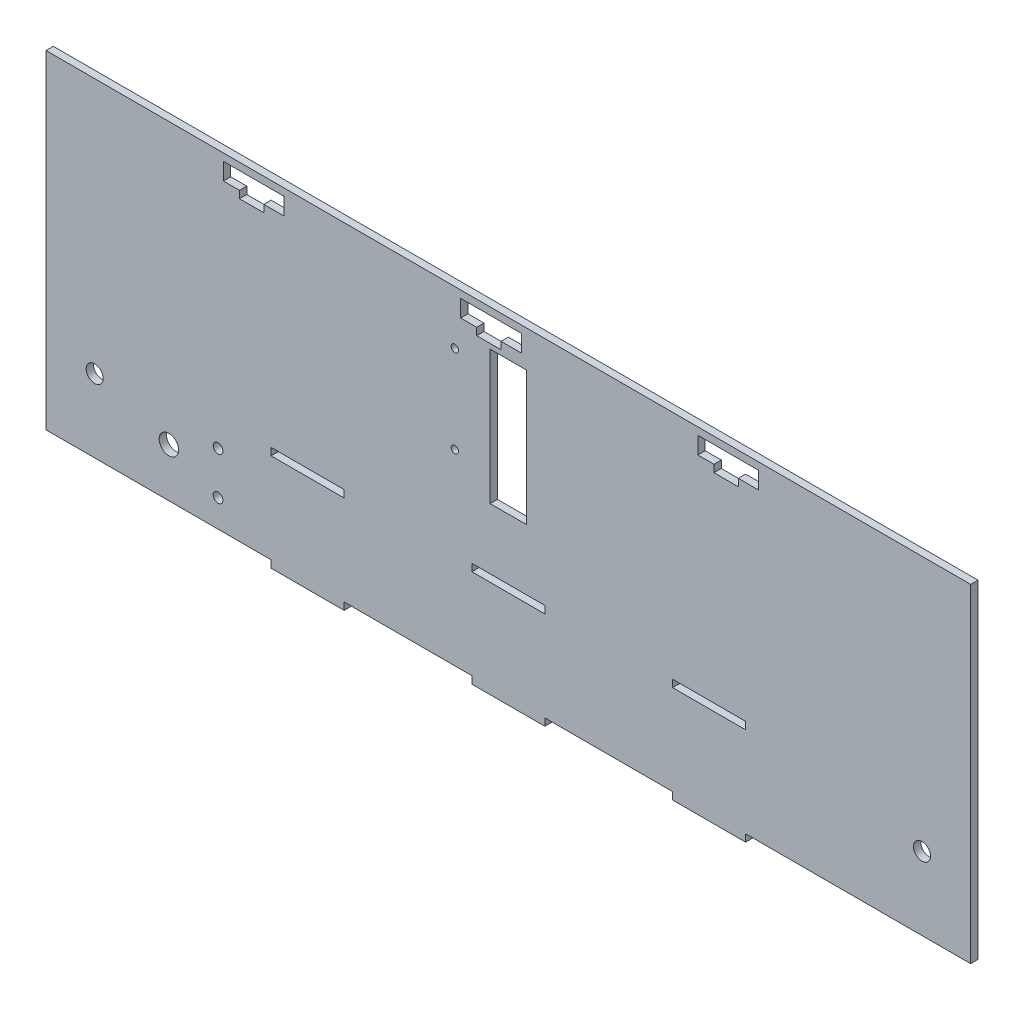
from build123d import *

# Parameters (mm, degrees)
CROQUIS1_R              = 1.5
CROQUIS1_R_2            = 3.5
CROQUIS1_R_3            = 4
CROQUIS1_R_4            = 2
CROQUIS1_W              = 30
CROQUIS1_H              = 3
CROQUIS1_W_2            = 15
CROQUIS1_H_2            = 55
SALIENTE_EXTRUIR4_DEPTH = 3


with BuildPart() as part:
    # Croquis1 → Saliente-Extruir4 (new body)
    with BuildSketch(Plane.XY):
        Polygon((-190, -67.5), (-97.5, -67.5), (-97.5, -70.5), (-67.5, -70.5), (-67.5, -67.5), (-15, -67.5), (-15, -70.5), (15, -70.5), (15, -67.5), (67.5, -67.5), (67.5, -70.5), (97.5, -70.5), (97.5, -67.5), (190, -67.5), (190, 67.5), (-190, 67.5), align=None)
        with Locations((-22, 45.5)):
            Circle(CROQUIS1_R, mode=Mode.SUBTRACT)
        with Locations((-22, 9.5)):
            Circle(CROQUIS1_R, mode=Mode.SUBTRACT)
        with Locations((-170, -37.5)):
            Circle(CROQUIS1_R_2, mode=Mode.SUBTRACT)
        with Locations((-139.5, -47.5)):
            Circle(CROQUIS1_R_3, mode=Mode.SUBTRACT)
        with Locations((-119.3, -38.75)):
            Circle(CROQUIS1_R_4, mode=Mode.SUBTRACT)
        with Locations((-119.3, -56.25)):
            Circle(CROQUIS1_R_4, mode=Mode.SUBTRACT)
        with Locations((170, -37.5)):
            Circle(CROQUIS1_R_2, mode=Mode.SUBTRACT)
        with Locations((82.5, -29)):
            Rectangle(CROQUIS1_W, CROQUIS1_H, mode=Mode.SUBTRACT)
        with Locations((0, -29)):
            Rectangle(CROQUIS1_W, CROQUIS1_H, mode=Mode.SUBTRACT)
        with Locations((-82.5, -29)):
            Rectangle(CROQUIS1_W, CROQUIS1_H, mode=Mode.SUBTRACT)
        Polygon((-19.6, 64.5), (-19.6, 57.5), (-13, 57.5), (-13, 54.5), (-3, 54.5), (-3, 57.5), (5.4, 57.5), (5.4, 64.5), align=None, mode=Mode.SUBTRACT)
        Polygon((-117.1, 64.5), (-117.1, 57.5), (-110.5, 57.5), (-110.5, 54.5), (-100.5, 54.5), (-100.5, 57.5), (-92.1, 57.5), (-92.1, 64.5), align=None, mode=Mode.SUBTRACT)
        Polygon((77.9, 64.5), (77.9, 57.5), (84.5, 57.5), (84.5, 54.5), (94.5, 54.5), (94.5, 57.5), (102.9, 57.5), (102.9, 64.5), align=None, mode=Mode.SUBTRACT)
        with Locations((0, 25)):
            Rectangle(CROQUIS1_W_2, CROQUIS1_H_2, mode=Mode.SUBTRACT)
    extrude(amount=SALIENTE_EXTRUIR4_DEPTH)


solid = part.part
